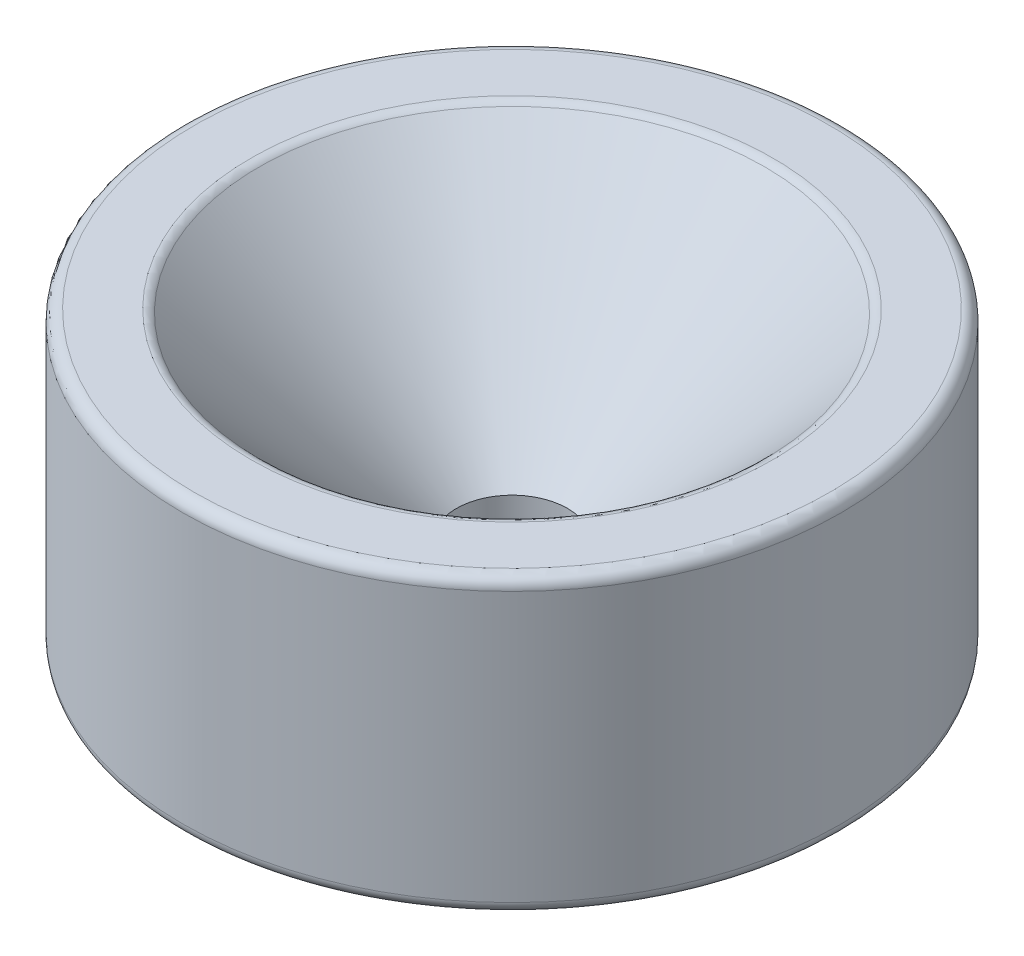
from build123d import *

# Parameters (mm, degrees)
CHAMFER1_SIZE = 0.381
FILLET1_R     = 0.508


with BuildPart() as part:
    # Sketch1 → Revolve1 (revolve)
    with BuildSketch(Plane.XY, mode=Mode.PRIVATE) as revolve1_sk:
        Polygon((2.413, 0.762), (8.763, 0.762), (9.525, 0), (14.2875, 0), (14.2875, 12.7), (11.1125, 12.7), (2.413, 4.0005), align=None)
    revolve(revolve1_sk.sketch.rotate(Axis((0, 0, 0), (0, 1, 0)), 90), axis=Axis((0, 0, 0), (0, 1, 0)))  # turned: the seam where the file's is

    # Chamfer1
    chamfer1_edges = [part.edges().sort_by_distance(p)[0] for p in [
        (0, 0.762, 2.413),
    ]]
    chamfer(chamfer1_edges, length=CHAMFER1_SIZE)

    # Fillet1
    fillet1_edges = [part.edges().sort_by_distance(p)[0] for p in [
        (0, 0, 14.2875),
        (0, 12.7, 14.2875),
        (0, 12.7, 11.1125),
    ]]
    fillet(fillet1_edges, radius=FILLET1_R)


solid = part.part
